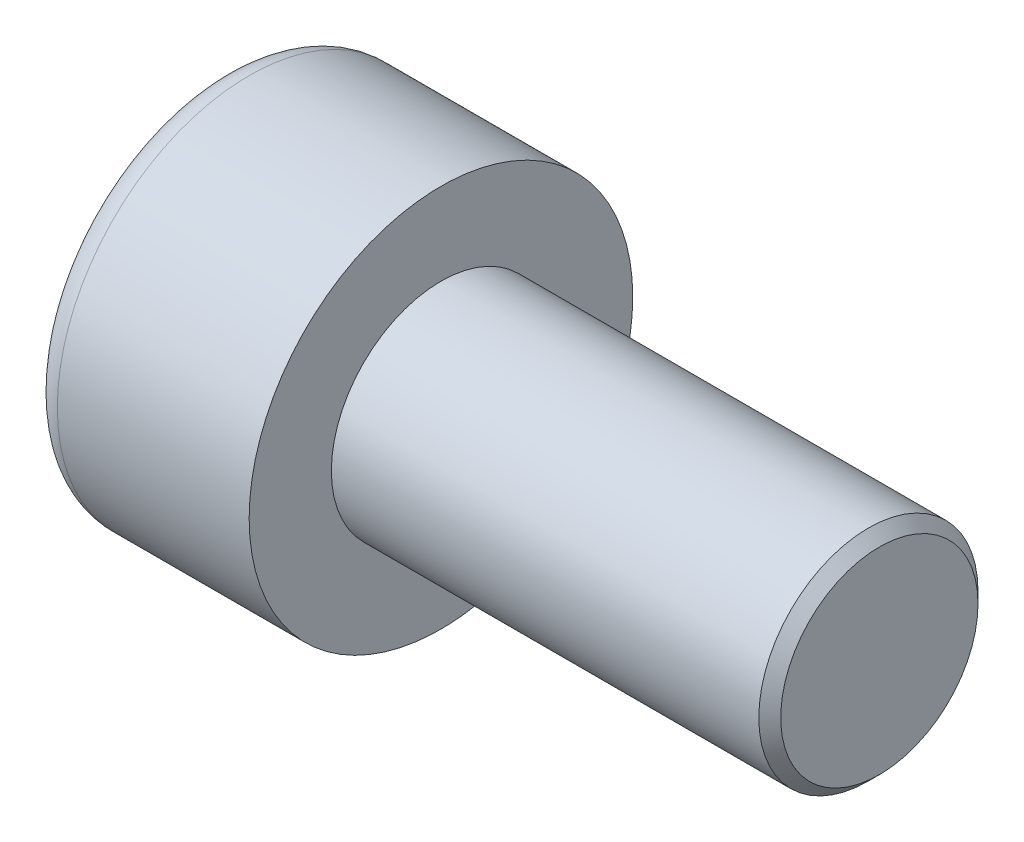
from build123d import *

# Parameters (mm, degrees)
SKETCH1_R           = 3.5
BASEHEAD_DEPTH      = 4
SKETCH2_R           = 2
BASEBODY_DEPTH      = 8
HEXAGONSOCKET_DEPTH = 2
TOPFILLET_R         = 0.5
CHAMFER1_SIZE       = 0.2


with BuildPart() as part:
    # Sketch1 → BaseHead (new body)
    with BuildSketch(Plane(origin=(0, 0, 0), x_dir=(0, 0, -1), z_dir=(1, 0, 0))):
        Circle(SKETCH1_R)
    extrude(amount=BASEHEAD_DEPTH)

    # Sketch2 → BaseBody (add)
    with BuildSketch(Plane(origin=(4, 0, 0), x_dir=(0, 0, -1), z_dir=(1, 0, 0))):
        Circle(SKETCH2_R)
    extrude(amount=BASEBODY_DEPTH)

    # Sketch3 → HexagonSocket (cut)
    with BuildSketch(Plane(origin=(0, 0, 0), x_dir=(0, 0, -1), z_dir=(1, 0, 0))):
        Polygon((1.732050808, 0), (0.866025404, 1.5), (-0.866025404, 1.5), (-1.732050808, 0), (-0.866025404, -1.5), (0.866025404, -1.5), align=None)
    extrude(amount=HEXAGONSOCKET_DEPTH, mode=Mode.SUBTRACT)

    # Sketch4 → Cut-Revolve1 (revolve, cut)
    with BuildSketch(Plane(origin=(-4.19613823, 0.75, 0), x_dir=(-1, 0, 0), z_dir=(0, 0, 1))):
        Polygon((-6.19613823, 2.25), (-7.062163633, 0.75), (-6.19613823, 0.75), align=None)
    revolve(axis=Axis((0.838992387, 0, 0), (-1, 0, 0)), mode=Mode.SUBTRACT)

    # TopFillet
    topfillet_edges = [part.edges().sort_by_distance(p)[0] for p in [
        (0, 0, 3.5),
    ]]
    fillet(topfillet_edges, radius=TOPFILLET_R)

    # Chamfer1
    chamfer1_edges = [part.edges().sort_by_distance(p)[0] for p in [
        (12, 0, 2),
    ]]
    chamfer(chamfer1_edges, length=CHAMFER1_SIZE)


solid = part.part
